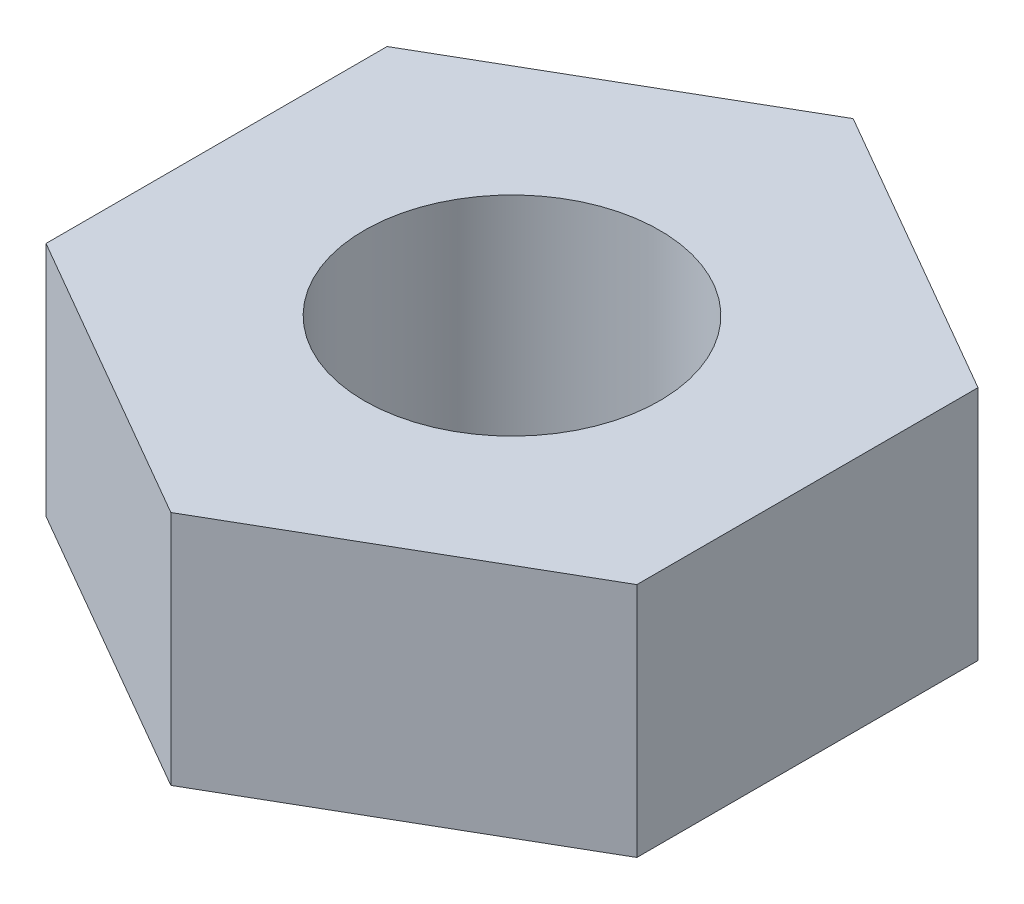
from build123d import *

# Parameters (mm, degrees)
SKETCH1_R           = 1
BOSS_EXTRUDE1_DEPTH = 1.6


with BuildPart() as part:
    # Sketch1 → Boss-Extrude1 (new body)
    with BuildSketch(Plane(origin=(0, 0, 0), x_dir=(1, 0, 0), z_dir=(0, 1, 0))):
        Polygon((2, -1.154700538), (2, 1.154700538), (0, 2.309401077), (-2, 1.154700538), (-2, -1.154700538), (0, -2.309401077), align=None)
        Circle(SKETCH1_R, mode=Mode.SUBTRACT)
    extrude(amount=BOSS_EXTRUDE1_DEPTH)


solid = part.part
